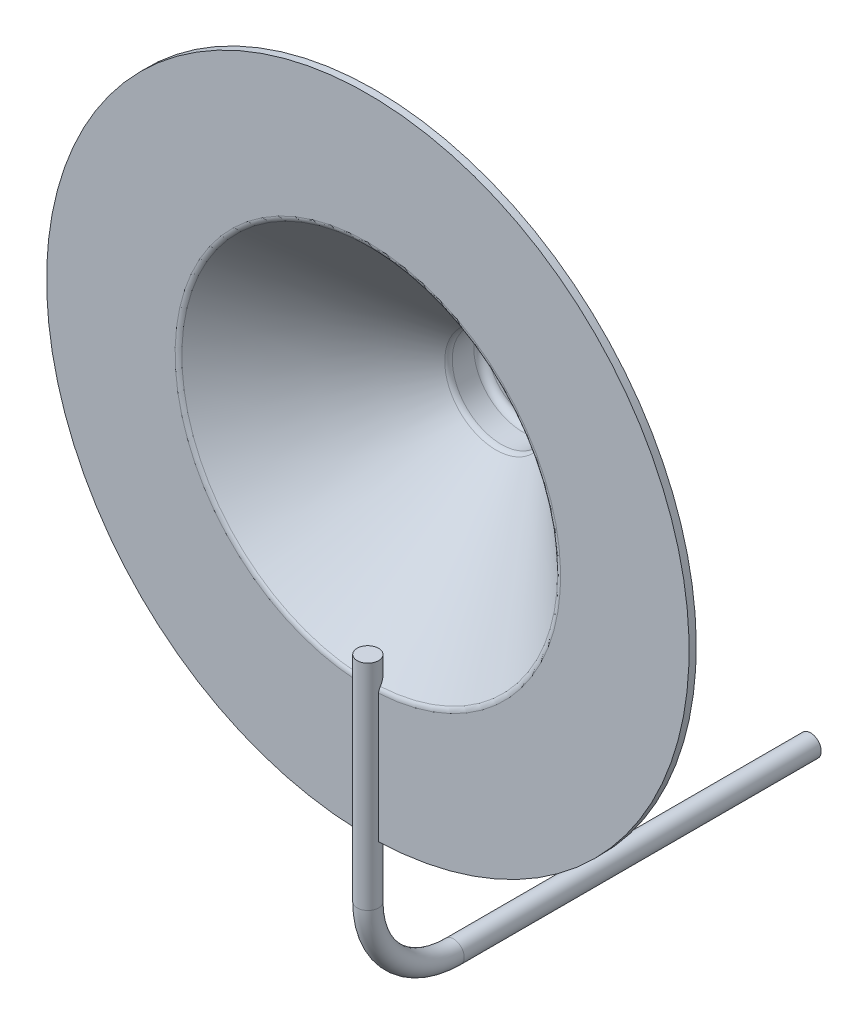
from build123d import *

# Parameters (mm, degrees)
SKETCH3_R = 0.15


with BuildPart() as part:
    # Sweep1: sweep along a path in Sketch4
    with BuildLine(Plane(origin=(0, 0, 0), x_dir=(0, 0, -1), z_dir=(1, 0, 0))) as sweep1_path:
        Line((0, -6.5), (-5, -6.5))
        ThreePointArc((-5, -6.5), (-5.848528137, -6.148528137), (-6.2, -5.3))
        Line((-6.2, -5.3), (-6.2, -2.3))
    # Sketch3 → Sweep1 (sweep)
    with BuildSketch(Plane.XY):
        with Locations((0, -6.5)):
            Circle(SKETCH3_R)
    sweep(path=sweep1_path.line)

    # Sketch6 → Revolve1 (revolve)
    with BuildSketch(Plane(origin=(0, 0, 0), x_dir=(0, 0, -1), z_dir=(1, 0, 0)), mode=Mode.PRIVATE) as revolve1_sk:
        with BuildLine():
            Line((-6.2, -4.5), (-6.2, -2.7))
            ThreePointArc((-6.2, -2.7), (-6.193121719, -2.663553527), (-6.173433093, -2.632120836))
            Line((-6.173433093, -2.632120836), (-4.404673955, -0.718640373))
            ThreePointArc((-4.404673955, -0.718640373), (-4.371316313, -0.69490099), (-4.331240862, -0.686519537))
            Line((-4.331240862, -0.686519537), (-4.031240862, -0.686519537))
            ThreePointArc((-4.031240862, -0.686519537), (-3.960530184, -0.657230215), (-3.931240862, -0.586519537))
            Line((-3.931240862, -0.586519537), (-3.931240862, 0))
            Line((-3.931240862, 0), (-3.831240862, 0))
            Line((-3.831240862, 0), (-3.831240862, -0.586519537))
            ThreePointArc((-3.831240862, -0.586519537), (-3.889819506, -0.727940893), (-4.031240862, -0.786519537))
            Line((-4.031240862, -0.786519537), (-4.331240862, -0.786519537))
            Line((-4.331240862, -0.786519537), (-6.1, -2.7))
            Line((-6.1, -2.7), (-6.1, -4.5))
            Line((-6.1, -4.5), (-6.2, -4.5))
        make_face()
    revolve(revolve1_sk.sketch.rotate(Axis((0, 0, 6.2), (0, 0, -1)), 270), axis=Axis((0, 0, 6.2), (0, 0, -1)))


solid = part.part
